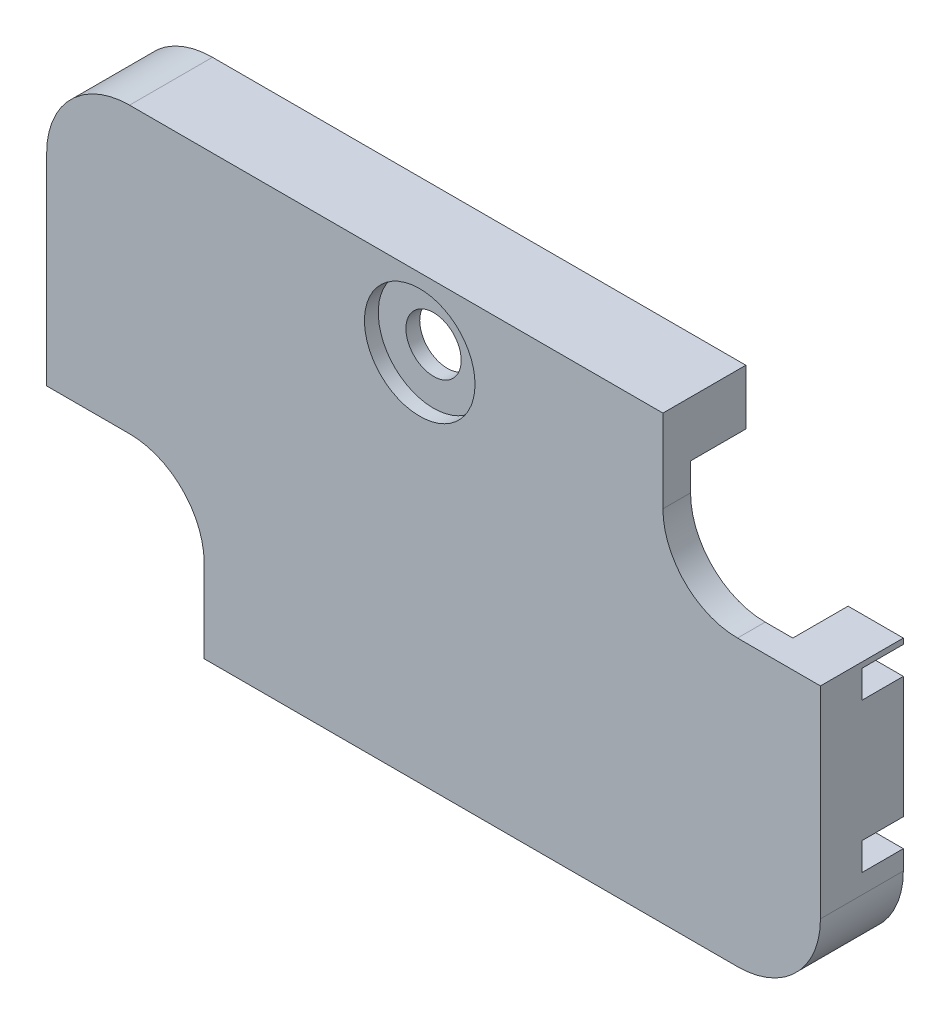
from build123d import *

# Parameters (mm, degrees)
DODANIE_WYCI_GNI_CIE1_DEPTH = 3
WYTNIJ_WYCI_GNI_CIE1_DEPTH  = 2
WYTNIJ_WYCI_GNI_CIE2_REACH  = 30
SZKIC3_W                    = 1.5
SZKIC3_H                    = 1
WYTNIJ_WYCI_GNI_CIE3_REACH  = 18
SZKIC4_W                    = 1
SZKIC4_H                    = 1.5
SZKIC5_R                    = 2
WYTNIJ_WYCI_GNI_CIE4_DEPTH  = 0.5
WYTNIJ_WYCI_GNI_CIE5_REACH  = 4.5
SZKIC6_R                    = 1


with BuildPart() as part:
    # Szkic1 → Dodanie-wyciągnięcie1 (new body)
    with BuildSketch(Plane.XY):
        with BuildLine():
            Line((-11, 8), (8.3, 8))
            Line((8.3, 8), (8.3, 5))
            ThreePointArc((8.3, 5), (9.090811691, 3.090811691), (11, 2.3))
            Line((11, 2.3), (14, 2.3))
            Line((14, 2.3), (14, -5))
            ThreePointArc((14, -5), (13.121320344, -7.121320344), (11, -8))
            Line((11, -8), (-8.3, -8))
            Line((-8.3, -8), (-8.3, -5))
            ThreePointArc((-8.3, -5), (-9.090811691, -3.090811691), (-11, -2.3))
            Line((-11, -2.3), (-14, -2.3))
            Line((-14, -2.3), (-14, 5))
            ThreePointArc((-14, 5), (-13.121320344, 7.121320344), (-11, 8))
        make_face()
    extrude(amount=DODANIE_WYCI_GNI_CIE1_DEPTH)

    # Szkic2 → Wytnij-wyciągnięcie1 (cut)
    with BuildSketch(Plane(origin=(0, 0, 0), x_dir=(-1, 0, 0), z_dir=(0, 0, -1))):
        with BuildLine():
            Line((11, 7), (-7.3, 7))
            ThreePointArc((-7.3, 7), (-8.007106781, 6.707106781), (-8.3, 6))
            Line((-8.3, 6), (-8.3, 5))
            ThreePointArc((-8.3, 5), (-9.090811691, 3.090811691), (-11, 2.3))
            Line((-11, 2.3), (-12, 2.3))
            ThreePointArc((-12, 2.3), (-12.707106781, 2.007106781), (-13, 1.3))
            Line((-13, 1.3), (-13, -5))
            ThreePointArc((-13, -5), (-12.414213562, -6.414213562), (-11, -7))
            Line((-11, -7), (7.3, -7))
            ThreePointArc((7.3, -7), (8.007106781, -6.707106781), (8.3, -6))
            Line((8.3, -6), (8.3, -5))
            ThreePointArc((8.3, -5), (9.090811691, -3.090811691), (11, -2.3))
            Line((11, -2.3), (12, -2.3))
            ThreePointArc((12, -2.3), (12.707106781, -2.007106781), (13, -1.3))
            Line((13, -1.3), (13, 5))
            ThreePointArc((13, 5), (12.414213562, 6.414213562), (11, 7))
        make_face()
    extrude(amount=-WYTNIJ_WYCI_GNI_CIE1_DEPTH, mode=Mode.SUBTRACT)

    # Szkic3 → Wytnij-wyciągnięcie2 (cut, up to next)
    with BuildSketch(Plane(origin=(14, 0, 0), x_dir=(0, 0, -1), z_dir=(1, 0, 0)), mode=Mode.PRIVATE) as wytnij_wyci_gni_cie2_sk1:
        with Locations((-0.75, 1.6)):
            Rectangle(SZKIC3_W, SZKIC3_H)
    wytnij_wyci_gni_cie2_tool1 = extrude(wytnij_wyci_gni_cie2_sk1.sketch, amount=-WYTNIJ_WYCI_GNI_CIE2_REACH, mode=Mode.PRIVATE) & part.part
    add(wytnij_wyci_gni_cie2_tool1.solids().sort_by_distance((14, 1.6, 0.75))[0], mode=Mode.SUBTRACT)
    # Szkic3 → Wytnij-wyciągnięcie2 (cut, up to next)
    with BuildSketch(Plane(origin=(14, 0, 0), x_dir=(0, 0, -1), z_dir=(1, 0, 0)), mode=Mode.PRIVATE) as wytnij_wyci_gni_cie2_sk2:
        with Locations((-0.75, -3.8)):
            Rectangle(SZKIC3_W, SZKIC3_H)
    wytnij_wyci_gni_cie2_tool2 = extrude(wytnij_wyci_gni_cie2_sk2.sketch, amount=-WYTNIJ_WYCI_GNI_CIE2_REACH, mode=Mode.PRIVATE) & part.part
    add(wytnij_wyci_gni_cie2_tool2.solids().sort_by_distance((14, -3.8, 0.75))[0], mode=Mode.SUBTRACT)

    # Szkic4 → Wytnij-wyciągnięcie3 (cut, up to next)
    with BuildSketch(Plane.XZ.offset(8), mode=Mode.PRIVATE) as wytnij_wyci_gni_cie3_sk1:
        with Locations((2, 0.75)):
            Rectangle(SZKIC4_W, SZKIC4_H)
    wytnij_wyci_gni_cie3_tool1 = extrude(wytnij_wyci_gni_cie3_sk1.sketch, amount=-WYTNIJ_WYCI_GNI_CIE3_REACH, mode=Mode.PRIVATE) & part.part
    add(wytnij_wyci_gni_cie3_tool1.solids().sort_by_distance((2, -8, 0.75))[0], mode=Mode.SUBTRACT)

    # Szkic5 → Wytnij-wyciągnięcie4 (cut)
    with BuildSketch(Plane.XY.offset(3)):
        with Locations((-0.5, 5.5)):
            Circle(SZKIC5_R)
    extrude(amount=-WYTNIJ_WYCI_GNI_CIE4_DEPTH, mode=Mode.SUBTRACT)

    # Szkic6 → Wytnij-wyciągnięcie5 (cut, up to next)
    with BuildSketch(Plane.XY.offset(2.5), mode=Mode.PRIVATE) as wytnij_wyci_gni_cie5_sk1:
        with Locations((-0.5, 5.5)):
            Circle(SZKIC6_R)
    wytnij_wyci_gni_cie5_tool1 = extrude(wytnij_wyci_gni_cie5_sk1.sketch, amount=-WYTNIJ_WYCI_GNI_CIE5_REACH, mode=Mode.PRIVATE) & part.part
    add(wytnij_wyci_gni_cie5_tool1.solids().sort_by_distance((-0.5, 5.5, 2.5))[0], mode=Mode.SUBTRACT)


solid = part.part
